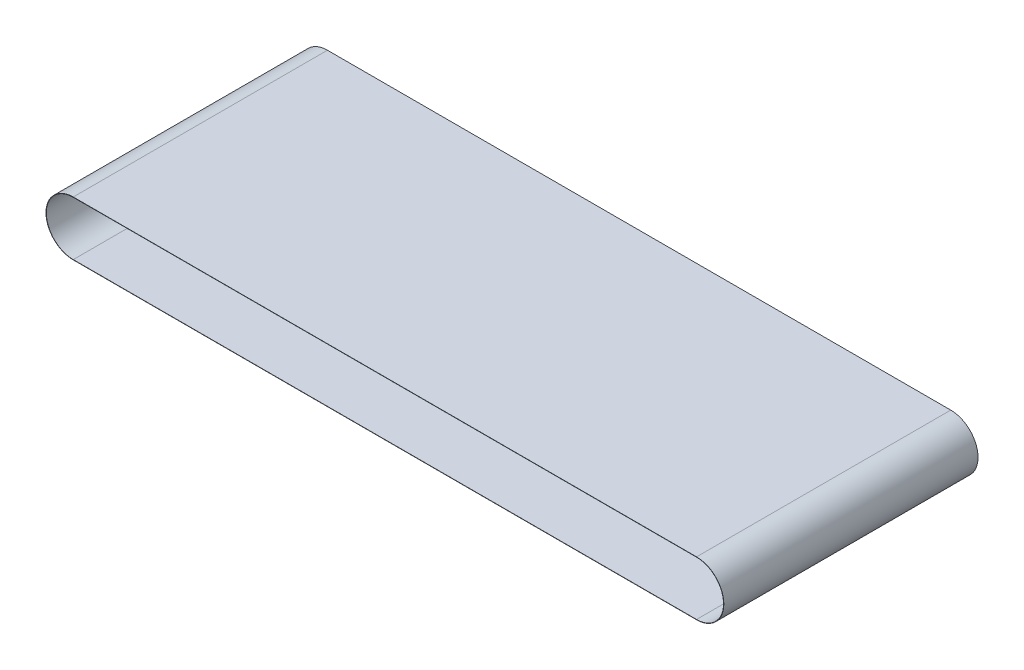
from build123d import *

# Parameters (mm, degrees)
BOSS_EXTRUDE1_DEPTH = 114.3


with BuildPart() as part:
    # Sketch1 → Boss-Extrude1 (new body, symmetric)
    with BuildSketch(Plane.XY):
        with BuildLine():
            Line((0, 24.511), (560.578, 24.511))
            ThreePointArc((560.578, 24.511), (585.089, 0), (560.578, -24.511))
            Line((560.578, -24.511), (0, -24.511))
            ThreePointArc((0, -24.511), (-24.511, 0), (0, 24.511))
        make_face()
        with BuildLine():
            Line((0, 24.257), (560.578, 24.257))
            ThreePointArc((560.578, 24.257), (584.835, 0), (560.578, -24.257))
            Line((560.578, -24.257), (0, -24.257))
            ThreePointArc((0, -24.257), (-24.257, 0), (0, 24.257))
        make_face(mode=Mode.SUBTRACT)
    extrude(amount=BOSS_EXTRUDE1_DEPTH, both=True)


solid = part.part
